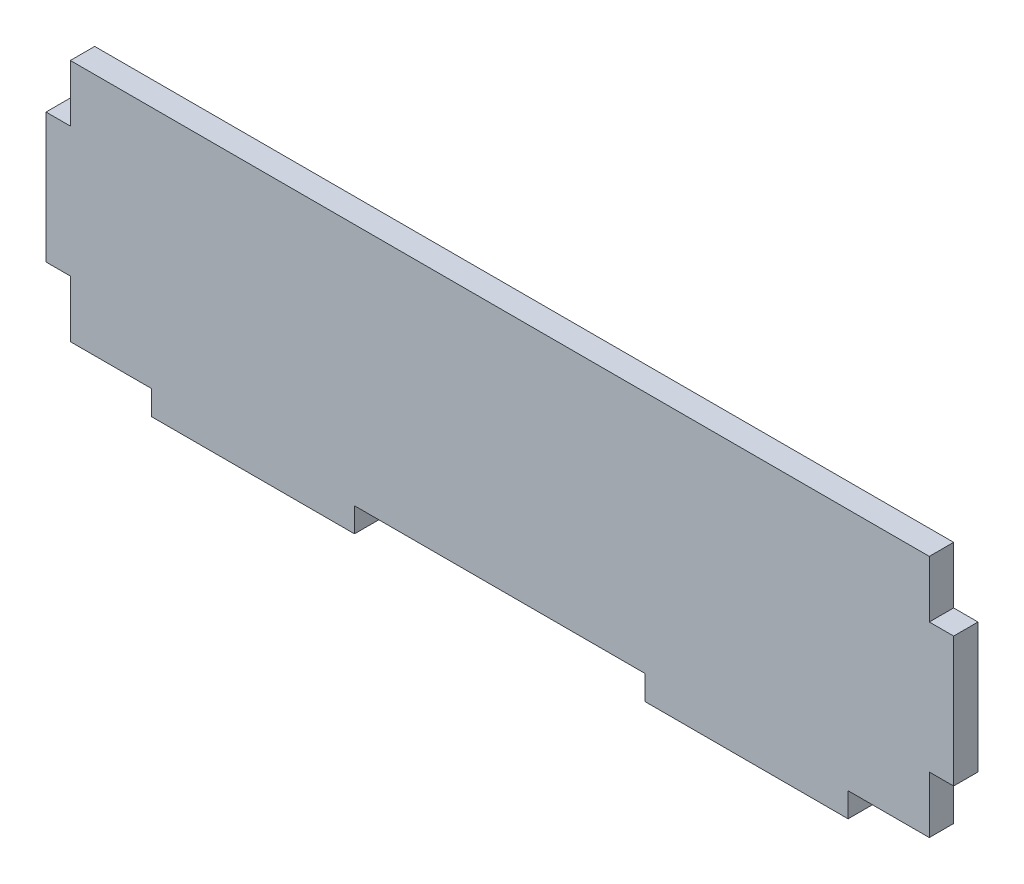
from build123d import *

# Parameters (mm, degrees)
EXTRUDE_1_DEPTH = 3


with BuildPart() as part:
    # 草图2 → 凸台-拉伸1 (new body)
    with BuildSketch(Plane.XY):
        Polygon((6.5, 0), (16.5, 0), (16.5, -3), (41.5, -3), (41.5, 0), (77.3, 0), (77.3, -3), (102.3, -3), (102.3, 0), (112.3, 0), (112.3, 7), (115.3, 7), (115.3, 23), (112.3, 23), (112.3, 30), (6.5, 30), (6.5, 23), (3.5, 23), (3.5, 7), (6.5, 7), align=None)
    extrude(amount=EXTRUDE_1_DEPTH)


solid = part.part
